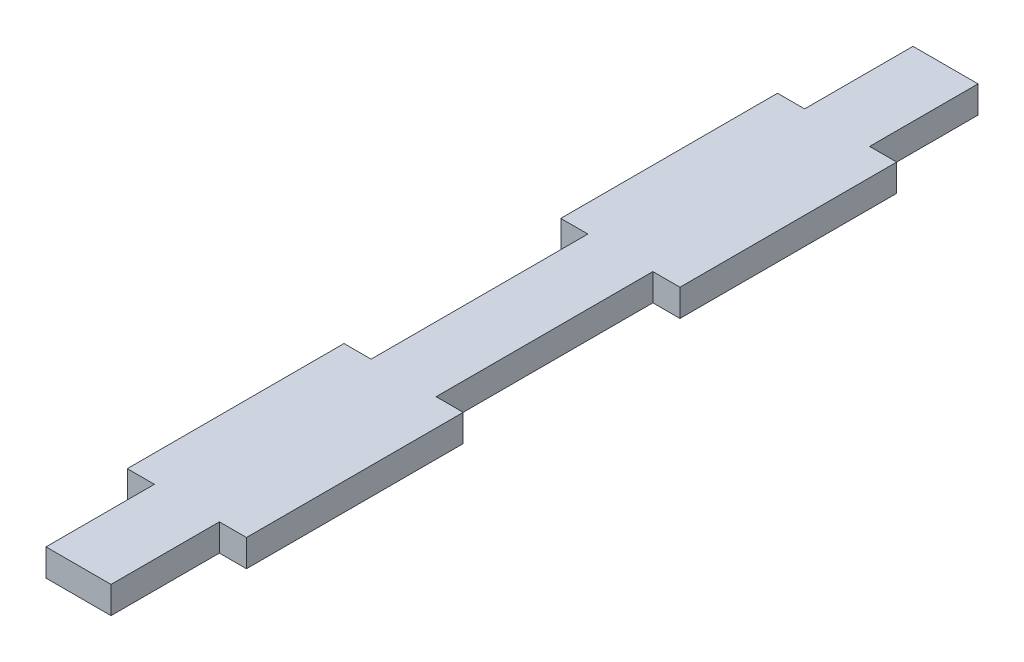
from build123d import *

# Parameters (mm, degrees)
BOSS_EXTRUDE2_DEPTH = 3.175


with BuildPart() as part:
    # Sketch1 → Boss-Extrude2 (new body)
    with BuildSketch(Plane(origin=(0, 0, 0), x_dir=(1, 0, 0), z_dir=(0, 1, 0))):
        Polygon((10.795, 38.1), (10.795, 12.7), (7.62, 12.7), (7.62, 0), (0, 0), (0, 12.7), (-3.175, 12.7), (-3.175, 38.1), (0, 38.1), (0, 63.5), (-3.175, 63.5), (-3.175, 88.9), (0, 88.9), (0, 101.6), (7.62, 101.6), (7.62, 88.9), (10.795, 88.9), (10.795, 63.5), (7.62, 63.5), (7.62, 38.1), align=None)
    extrude(amount=BOSS_EXTRUDE2_DEPTH)


solid = part.part
